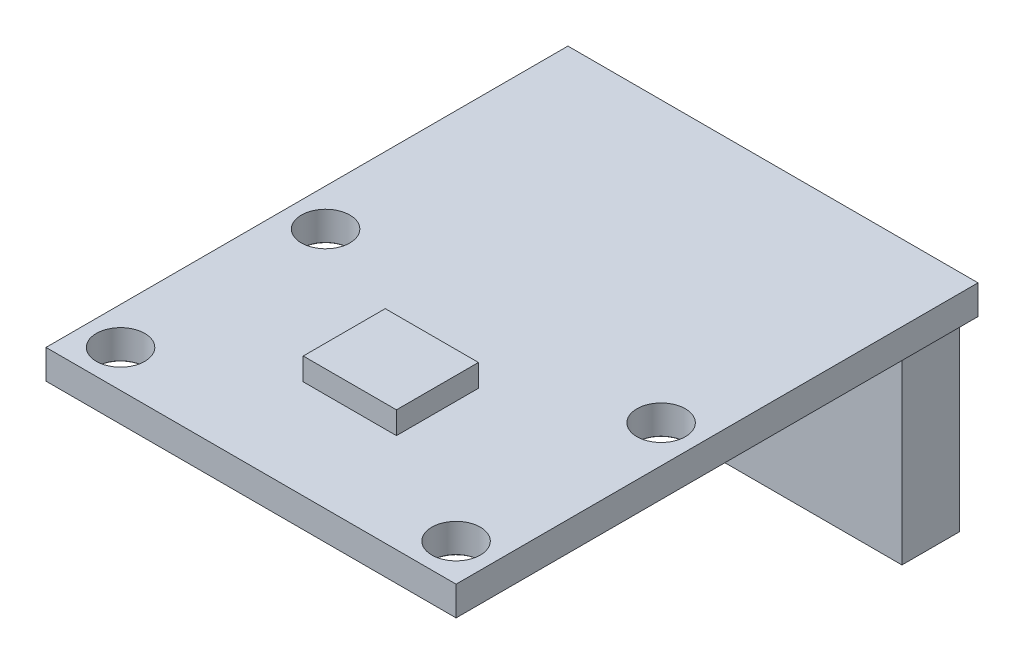
from build123d import *

# Parameters (mm, degrees)
SKETCH1_W                           = 22
SKETCH1_H                           = 28
BOSS_EXTRUDE1_DEPTH                 = 1.57
F_2_6_2_6_DIAMETER_HOLE1_AT_2_COUNT = 2
F_2_6_2_6_DIAMETER_HOLE1_AT_2_PITCH = 11
F_2_6_2_6_DIAMETER_HOLE1_AT_3_COUNT = 2
F_2_6_2_6_DIAMETER_HOLE1_AT_3_PITCH = 21.09502311
F_2_6_2_6_DIAMETER_HOLE1_AT_4_COUNT = 2
F_2_6_2_6_DIAMETER_HOLE1_AT_4_PITCH = 18
SKETCH5_W                           = 5
SKETCH5_H                           = 4.4
BOSS_EXTRUDE2_DEPTH                 = 1.2
SKETCH6_W                           = 21
SKETCH6_H                           = 3.08
BOSS_EXTRUDE3_DEPTH                 = 10


with BuildPart() as part:
    # Sketch1 → Boss-Extrude1 (new body)
    with BuildSketch(Plane(origin=(0, 0, 0), x_dir=(1, 0, 0), z_dir=(0, 1, 0))):
        with Locations((0, 6.5)):
            Rectangle(SKETCH1_W, SKETCH1_H)
    extrude(amount=BOSS_EXTRUDE1_DEPTH)

    # Sketch3 → Ø2.6 (2.6) Diameter Hole1 (revolve, cut)
    with BuildSketch(Plane(origin=(-9, 1.57, -5.5), x_dir=(0, 0, 1), z_dir=(1, 0, 0))):
        Polygon((0, 0), (0, 1.57), (1.325, 1.57), (1.3, 1.545), (1.3, 0), align=None)
    f_2_6_2_6_diameter_hole1 = revolve(axis=Axis((-9, 7.92, -5.5), (0, -1, 0)), mode=Mode.SUBTRACT)

    # Ø2.6 (2.6) Diameter Hole1 at 2: Ø2.6 (2.6) Diameter Hole1 ×2
    with Locations(*[(0, 0, i * F_2_6_2_6_DIAMETER_HOLE1_AT_2_PITCH) for i in range(1, F_2_6_2_6_DIAMETER_HOLE1_AT_2_COUNT)]):
        add(f_2_6_2_6_diameter_hole1, mode=Mode.SUBTRACT)

    # Ø2.6 (2.6) Diameter Hole1 at 3: Ø2.6 (2.6) Diameter Hole1 ×2
    with Locations(*[Vector(0.853281834, 0, 0.521450009) * (i * F_2_6_2_6_DIAMETER_HOLE1_AT_3_PITCH) for i in range(1, F_2_6_2_6_DIAMETER_HOLE1_AT_3_COUNT)]):
        add(f_2_6_2_6_diameter_hole1, mode=Mode.SUBTRACT)

    # Ø2.6 (2.6) Diameter Hole1 at 4: Ø2.6 (2.6) Diameter Hole1 ×2
    with Locations(*[(i * F_2_6_2_6_DIAMETER_HOLE1_AT_4_PITCH, 0, 0) for i in range(1, F_2_6_2_6_DIAMETER_HOLE1_AT_4_COUNT)]):
        add(f_2_6_2_6_diameter_hole1, mode=Mode.SUBTRACT)

    # Sketch5 → Boss-Extrude2 (add)
    with BuildSketch(Plane(origin=(0, 1.57, 0), x_dir=(1, 0, 0), z_dir=(0, 1, 0))):
        Rectangle(SKETCH5_W, SKETCH5_H)
    extrude(amount=BOSS_EXTRUDE2_DEPTH)

    # Sketch6 → Boss-Extrude3 (add)
    with BuildSketch(Plane(origin=(0, 0, 0), x_dir=(1, 0, 0), z_dir=(0, 1, 0))):
        with Locations((0, 18.46)):
            Rectangle(SKETCH6_W, SKETCH6_H)
    extrude(amount=-BOSS_EXTRUDE3_DEPTH)


solid = part.part
